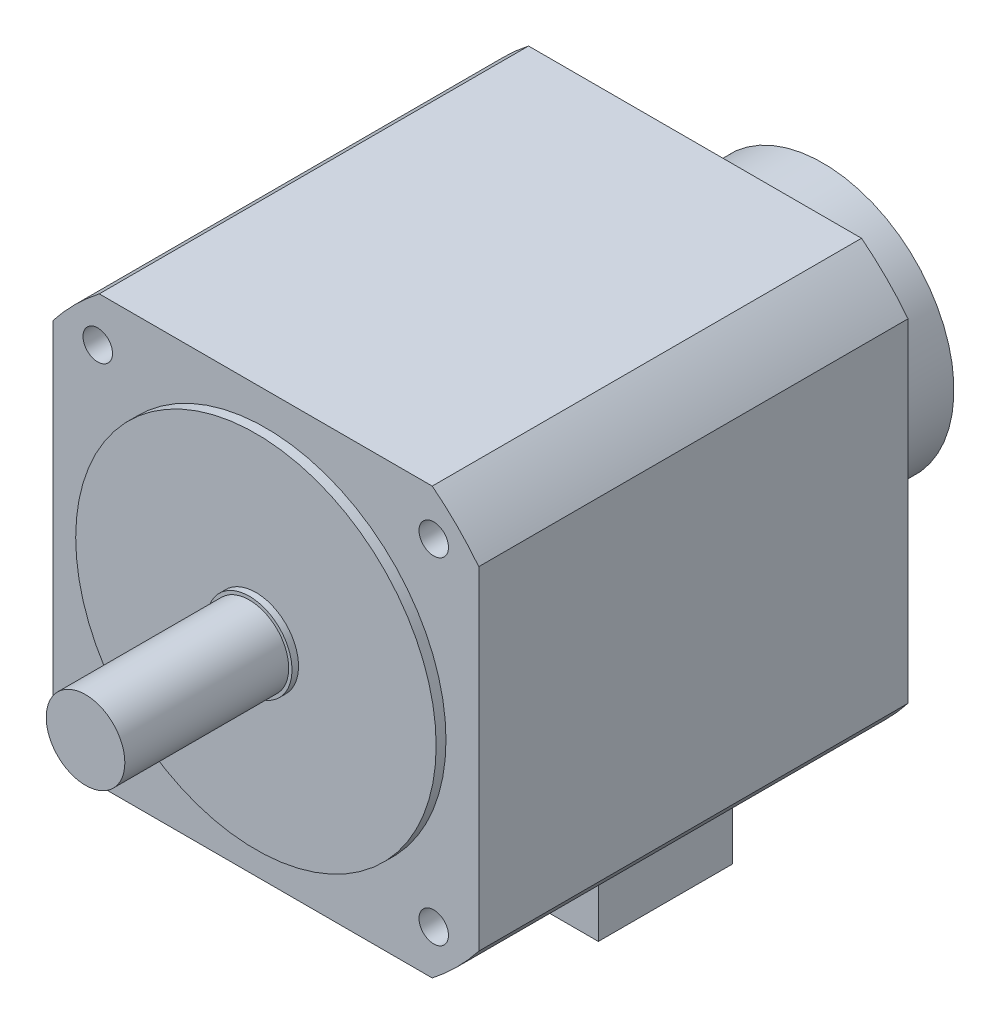
from build123d import *

# Parameters (mm, degrees)
SKETCH1_R           = 12
BOSS_EXTRUDE1_DEPTH = 50
SKETCH2_R           = 13
BOSS_EXTRUDE2_DEPTH = 2
SKETCH3_R           = 55
BOSS_EXTRUDE3_DEPTH = 3
BOSS_EXTRUDE4_DEPTH = 131
BOSS_EXTRUDE5_DEPTH = 39
SKETCH6_R           = 4.5
CUT_EXTRUDE1_DEPTH  = 15
SKETCH7_W           = 41
SKETCH7_H           = 41
BOSS_EXTRUDE6_DEPTH = 46


with BuildPart() as part:
    # Sketch1 → Boss-Extrude1 (new body)
    with BuildSketch(Plane.XY):
        Circle(SKETCH1_R)
    extrude(amount=-BOSS_EXTRUDE1_DEPTH)

    # Sketch2 → Boss-Extrude2 (add)
    with BuildSketch(Plane(origin=(0, 0, -50), x_dir=(-1, 0, 0), z_dir=(0, 0, -1))):
        Circle(SKETCH2_R)
    extrude(amount=BOSS_EXTRUDE2_DEPTH)

    # Sketch3 → Boss-Extrude3 (add)
    with BuildSketch(Plane(origin=(0, 0, -52), x_dir=(-1, 0, 0), z_dir=(0, 0, -1))):
        Circle(SKETCH3_R)
    extrude(amount=BOSS_EXTRUDE3_DEPTH)

    # Sketch4 → Boss-Extrude4 (add)
    with BuildSketch(Plane(origin=(0, 0, -55), x_dir=(-1, 0, 0), z_dir=(0, 0, -1))):
        with BuildLine():
            Line((-50.806003582, -65), (50.806003582, -65))
            ThreePointArc((50.806003582, -65), (58.336309448, -58.336309448), (65, -50.806003582))
            Line((65, -50.806003582), (65, 50.806003582))
            ThreePointArc((65, 50.806003582), (58.336309448, 58.336309448), (50.806003582, 65))
            Line((50.806003582, 65), (-50.806003582, 65))
            ThreePointArc((-50.806003582, 65), (-58.336309448, 58.336309448), (-65, 50.806003582))
            Line((-65, 50.806003582), (-65, -50.806003582))
            ThreePointArc((-65, -50.806003582), (-58.336309448, -58.336309448), (-50.806003582, -65))
        make_face()
    extrude(amount=BOSS_EXTRUDE4_DEPTH)

    # Sketch5 → Boss-Extrude5 (add)
    with BuildSketch(Plane(origin=(0, 0, -186), x_dir=(-1, 0, 0), z_dir=(0, 0, -1))):
        with BuildLine():
            Line((-19.5, -34.92491947), (-19.5, -81.5))
            Line((-19.5, -81.5), (19.5, -81.5))
            Line((19.5, -81.5), (19.5, -34.92491947))
            ThreePointArc((19.5, -34.92491947), (0, 40), (-19.5, -34.92491947))
        make_face()
    extrude(amount=BOSS_EXTRUDE5_DEPTH)

    # Sketch6 → Cut-Extrude1 (cut)
    with BuildSketch(Plane.XY.offset(-55)):
        with Locations((-51.265241636, 51.265241636)):
            Circle(SKETCH6_R)
        with Locations((51.265241636, 51.265241636)):
            Circle(SKETCH6_R)
        with Locations((51.265241636, -51.265241636)):
            Circle(SKETCH6_R)
        with Locations((-51.265241636, -51.265241636)):
            Circle(SKETCH6_R)
    extrude(amount=-CUT_EXTRUDE1_DEPTH, mode=Mode.SUBTRACT)

    # Sketch7 → Boss-Extrude6 (add)
    with BuildSketch(Plane.XZ.offset(65)):
        with Locations((0, -156.5)):
            Rectangle(SKETCH7_W, SKETCH7_H)
    extrude(amount=BOSS_EXTRUDE6_DEPTH)


solid = part.part
